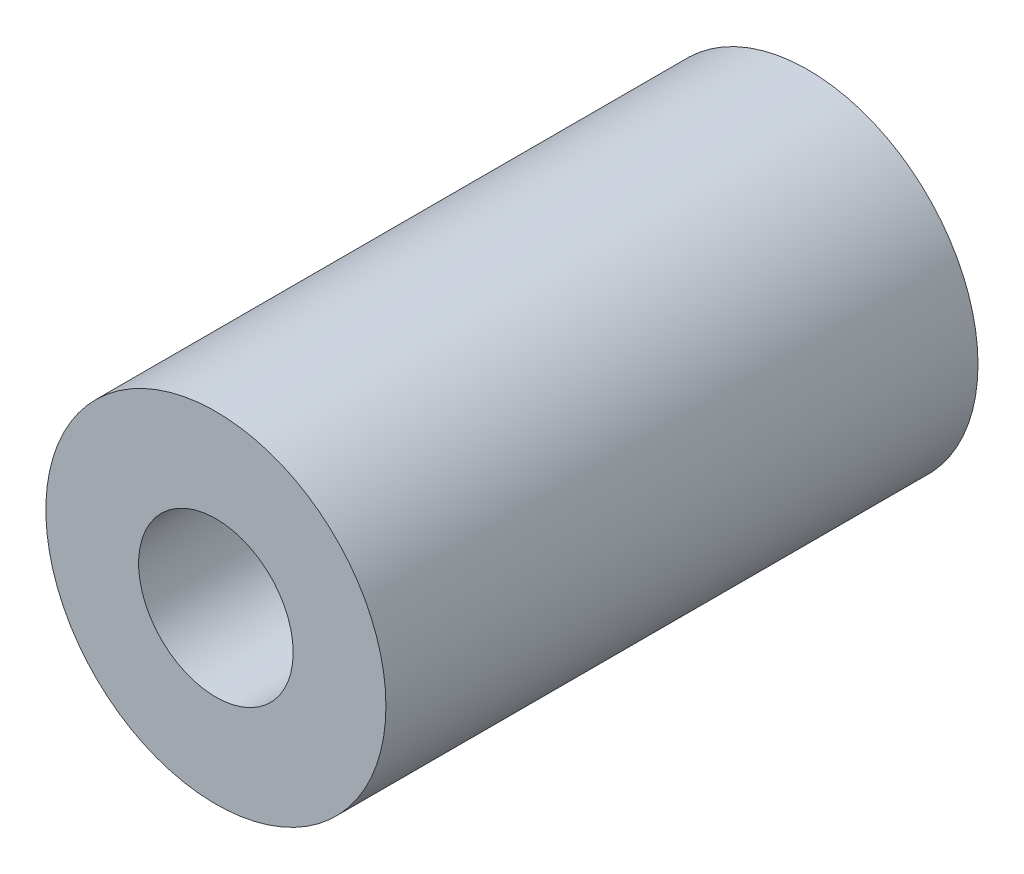
from build123d import *

# Parameters (mm, degrees)
SKETCH1_R           = 5.5
SKETCH1_R_2         = 2.5
BOSS_EXTRUDE1_DEPTH = 19.15


with BuildPart() as part:
    # Sketch1 → Boss-Extrude1 (new body)
    with BuildSketch(Plane.XY):
        Circle(SKETCH1_R)
        Circle(SKETCH1_R_2, mode=Mode.SUBTRACT)
    extrude(amount=BOSS_EXTRUDE1_DEPTH)


solid = part.part
